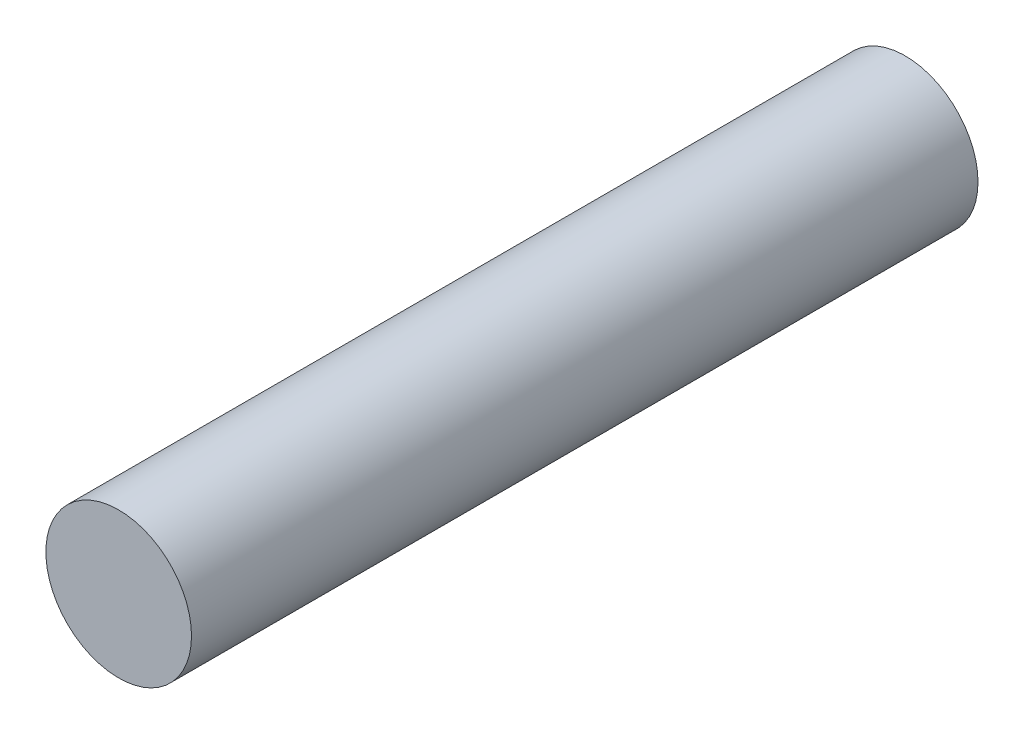
from build123d import *

# Parameters (mm, degrees)
SKETCH1_R           = 12.5
BOSS_EXTRUDE1_DEPTH = 135


with BuildPart() as part:
    # Sketch1 → Boss-Extrude1 (new body)
    with BuildSketch(Plane.XY):
        Circle(SKETCH1_R)
    extrude(amount=BOSS_EXTRUDE1_DEPTH)


solid = part.part
